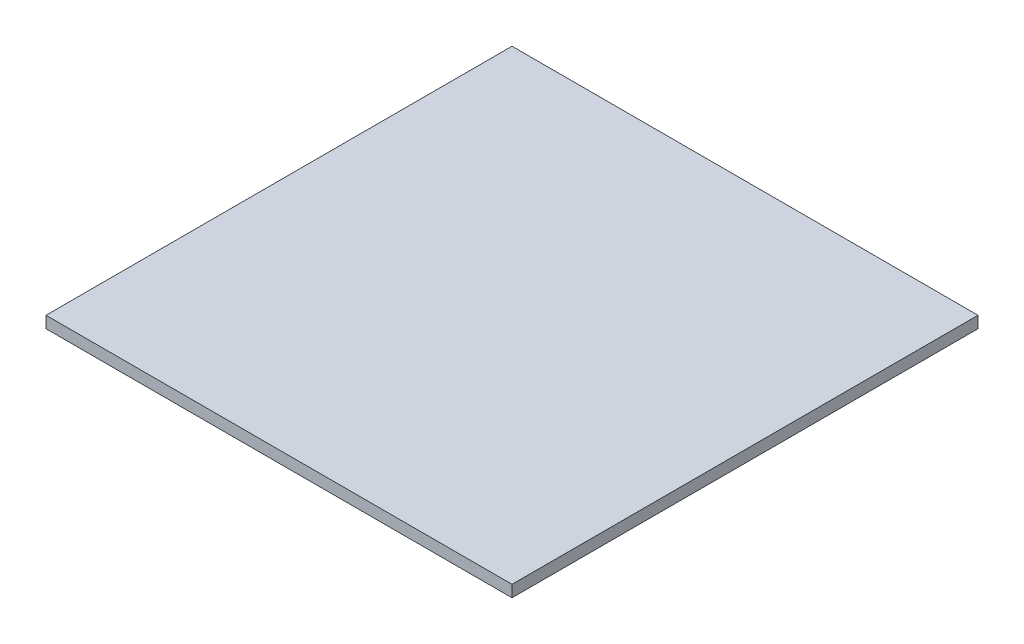
from build123d import *

# Parameters (mm, degrees)
SKETCH1_W           = 457.2
SKETCH1_H           = 457.2
BOSS_EXTRUDE1_DEPTH = 11.4554


with BuildPart() as part:
    # Sketch1 → Boss-Extrude1 (new body)
    with BuildSketch(Plane(origin=(0, 0, 0), x_dir=(1, 0, 0), z_dir=(0, 1, 0))):
        Rectangle(SKETCH1_W, SKETCH1_H)
    extrude(amount=BOSS_EXTRUDE1_DEPTH)


solid = part.part
